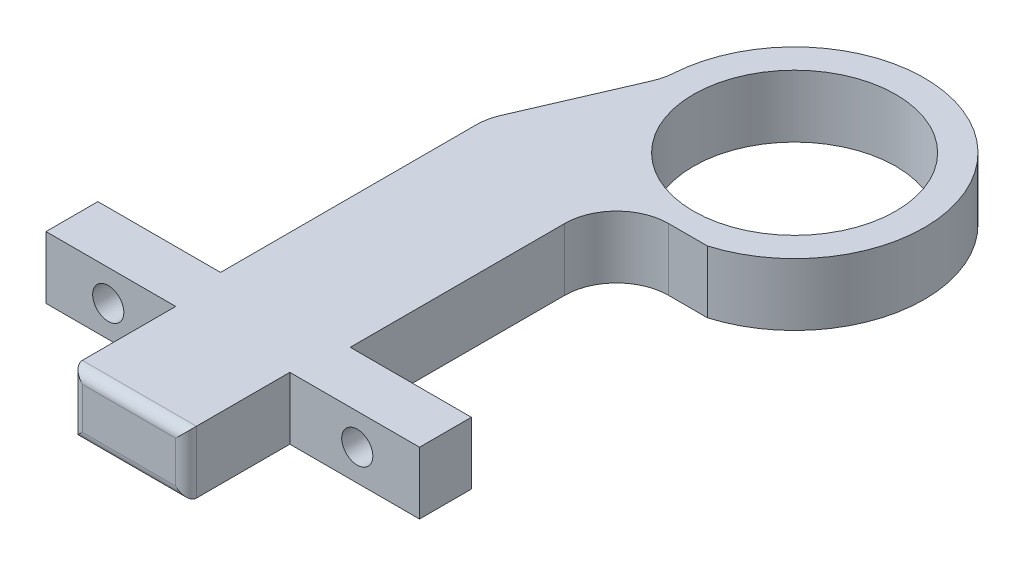
from build123d import *

# Parameters (mm, degrees)
CROQUIS1_R              = 9.75
SALIENTE_EXTRUIR1_DEPTH = 6
CROQUIS2_R              = 1.5
CORTAR_EXTRUIR1_DEPTH   = 6
REDONDEO1_R             = 1


with BuildPart() as part:
    # Croquis1 → Saliente-Extruir1 (new body)
    with BuildSketch(Plane(origin=(0, 0, 0), x_dir=(1, 0, 0), z_dir=(0, 1, 0))):
        with BuildLine():
            Line((-25.374701647, 20.783734094), (-29.767291136, 10.621141392))
            ThreePointArc((-29.767291136, 10.621141392), (-29.942112128, 10.153967486), (-30.069514751, 9.671699501))
            ThreePointArc((-30.069514751, 9.671699501), (-30.150557328, 9.157351254), (-30.17766953, 8.637363805))
            Line((-30.17766953, 8.637363805), (-30.17766953, -16))
            Line((-30.17766953, -16), (-42, -16))
            Line((-42, -16), (-42, -21))
            Line((-42, -21), (-29.5, -21))
            Line((-29.5, -21), (-29.5, -31))
            Line((-29.5, -31), (-18.5, -31))
            Line((-18.5, -31), (-18.5, -21))
            Line((-18.5, -21), (-6, -21))
            Line((-6, -21), (-6, -16))
            Line((-6, -16), (-17.67766953, -16))
            Line((-17.67766953, -16), (-17.67766953, 4.671699501))
            ThreePointArc((-17.67766953, 4.671699501), (-16.213203436, 8.207233407), (-12.67766953, 9.671699501))
            Line((-12.67766953, 9.671699501), (-8.928571429, 9.671699501))
            ThreePointArc((-8.928571429, 9.671699501), (-4.713647249, 31.429321655), (-24.974516609, 22.448404084))
            ThreePointArc((-24.974516609, 22.448404084), (-25.102827296, 21.598812807), (-25.374701647, 20.783734094))
        make_face()
        with Locations((-12.5, 21.650635095)):
            Circle(CROQUIS1_R, mode=Mode.SUBTRACT)
    extrude(amount=SALIENTE_EXTRUIR1_DEPTH)

    # Croquis2 → Cortar-Extruir1 (cut)
    with BuildSketch(Plane.XY.offset(21)):
        with Locations((-36, 3)):
            Circle(CROQUIS2_R)
        with Locations((-12, 3)):
            Circle(CROQUIS2_R)
    extrude(amount=-CORTAR_EXTRUIR1_DEPTH, mode=Mode.SUBTRACT)

    # Redondeo1
    redondeo1_edges = [part.edges().sort_by_distance(p)[0] for p in [
        (-24, 0, 31),
        (-18.5, 3, 31),
        (-29.5, 3, 31),
        (-24, 6, 31),
    ]]
    fillet(redondeo1_edges, radius=REDONDEO1_R)


solid = part.part
